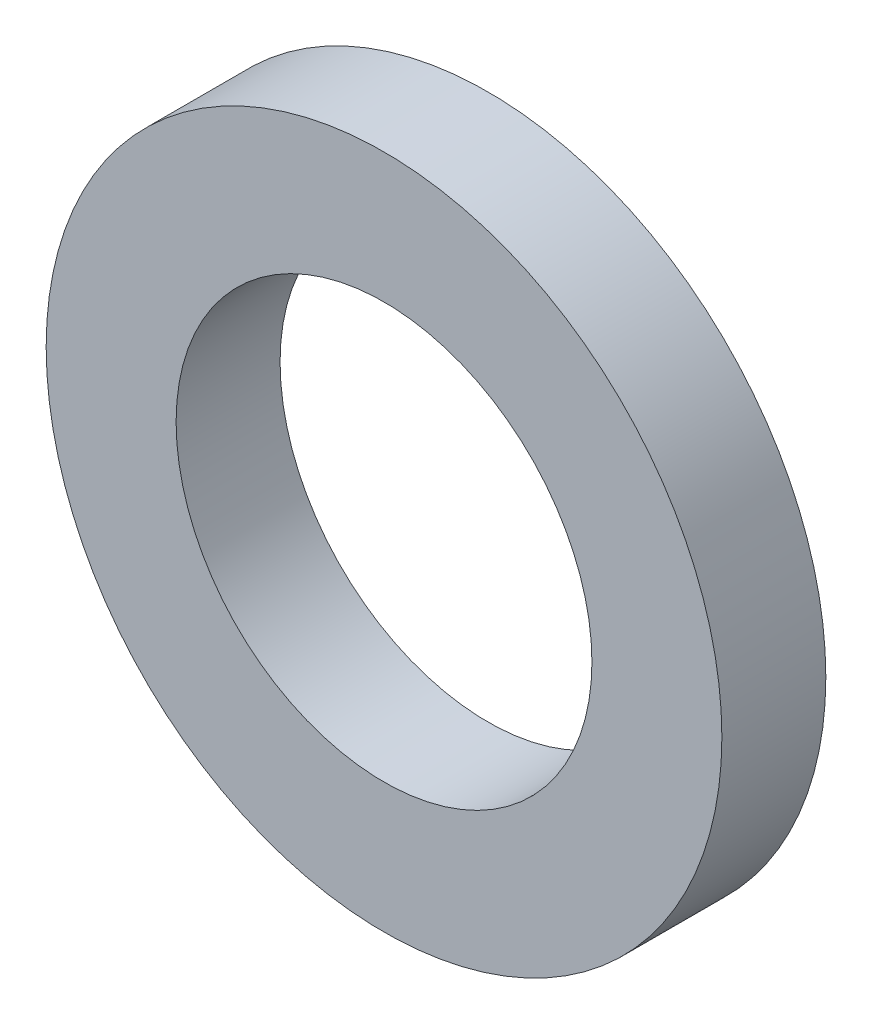
from build123d import *

# Parameters (mm, degrees)
SKETCH1_R           = 6.5
SKETCH1_R_2         = 4
BOSS_EXTRUDE1_DEPTH = 2


with BuildPart() as part:
    # Sketch1 → Boss-Extrude1 (new body)
    with BuildSketch(Plane.XY):
        Circle(SKETCH1_R)
        Circle(SKETCH1_R_2, mode=Mode.SUBTRACT)
    extrude(amount=BOSS_EXTRUDE1_DEPTH)


solid = part.part
